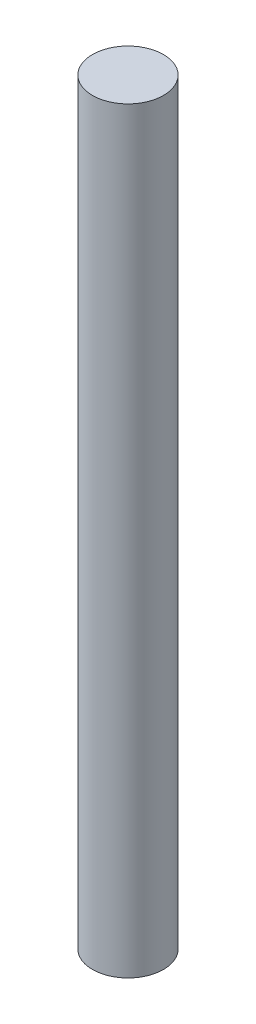
from build123d import *

# Parameters (mm, degrees)
SKETCH1_R           = 4.7625
BOSS_EXTRUDE1_DEPTH = 101.6


with BuildPart() as part:
    # Sketch1 → Boss-Extrude1 (new body)
    with BuildSketch(Plane(origin=(0, 0, 0), x_dir=(1, 0, 0), z_dir=(0, 1, 0))):
        Circle(SKETCH1_R)
    extrude(amount=BOSS_EXTRUDE1_DEPTH)


solid = part.part
